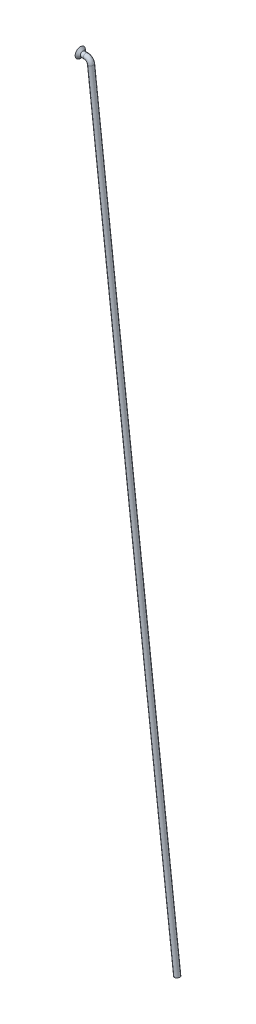
from build123d import *

# Parameters (mm, degrees)
ESQUISSE2_R = 1


with BuildPart() as part:
    # Balayage1: sweep along a path in Esquisse1
    with BuildLine(Plane.XY) as balayage1_path:
        Line((-4, 0), (-1.78256126, 0))
        ThreePointArc((-1.78256126, 0), (-0.451839945, -0.506955867), (0.204264392, -1.770819218))
        Line((0.204264392, -1.770819218), (33.804165342, -293.056783586))
    # Esquisse2 → Balayage1 (sweep)
    with BuildSketch(Plane(origin=(-4, 0, 0), x_dir=(0, 0, -1), z_dir=(1, 0, 0))):
        Circle(ESQUISSE2_R)
    sweep(path=balayage1_path.line)

    # Esquisse3 → Révolution1 (revolve)
    with BuildSketch(Plane.XY):
        Polygon((-4, 1), (-4, 2), (-3, 1), align=None)
    revolve(axis=Axis((0, 0, 0), (-1, 0, 0)))


solid = part.part
